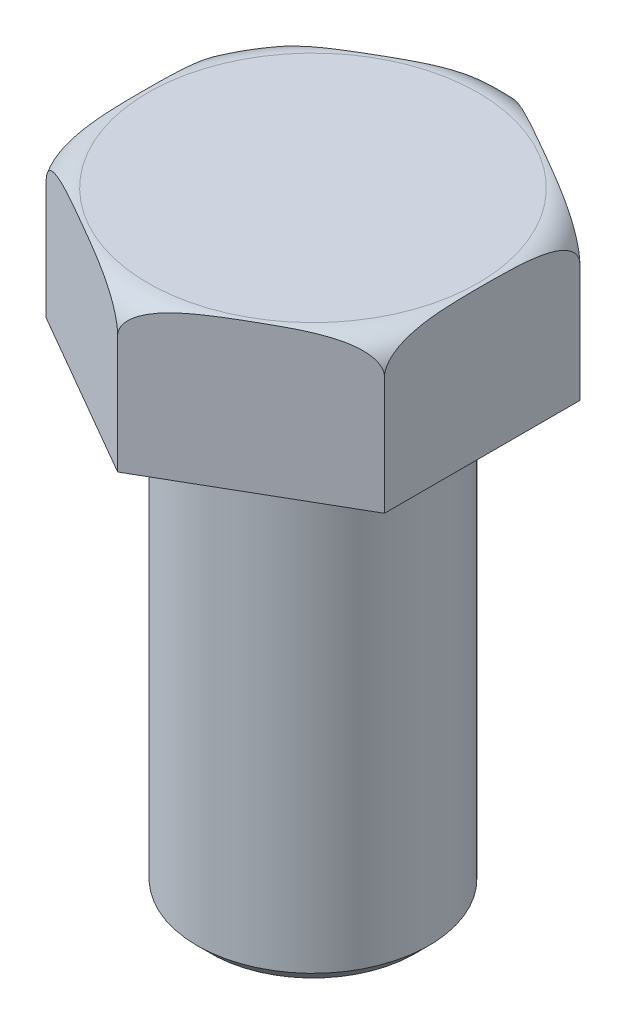
from build123d import *

# Parameters (mm, degrees)
EXTRUDE1_DEPTH = 8.128
SKETCH3_R      = 6.35
EXTRUDE2_DEPTH = 25.4
CHAMFER1_SIZE  = 0.762


with BuildPart() as part:
    # Sketch1 → Extrude1 (new body)
    with BuildSketch(Plane(origin=(0, 0, 0), x_dir=(1, 0, 0), z_dir=(0, 1, 0))):
        Polygon((0, 10.697481421), (-9.264290667, 5.34874071), (-9.264290667, -5.34874071), (0, -10.697481421), (9.264290667, -5.34874071), (9.264290667, 5.34874071), align=None)
    extrude(amount=EXTRUDE1_DEPTH)

    # Sketch3 → Extrude2 (add)
    with BuildSketch(Plane.XZ):
        Circle(SKETCH3_R)
    extrude(amount=EXTRUDE2_DEPTH)

    # Sketch2 → Cut-Revolve1 (revolve, cut)
    with BuildSketch(Plane(origin=(0, 0, 0), x_dir=(0, 0, -1), z_dir=(1, 0, 0))):
        with BuildLine():
            Line((9.038030353, 8.128), (10.697481421, 8.128))
            Line((10.697481421, 8.128), (10.697481421, 6.468548932))
            ThreePointArc((10.697481421, 6.468548932), (10.211439456, 7.641958035), (9.038030353, 8.128))
        make_face()
    revolve(axis=Axis((0, -25.4, 0), (0, 1, 0)), mode=Mode.SUBTRACT)

    # Chamfer1
    chamfer1_edges = [part.edges().sort_by_distance(p)[0] for p in [
        (-6.35, -25.4, 0),
    ]]
    chamfer(chamfer1_edges, length=CHAMFER1_SIZE)


solid = part.part
